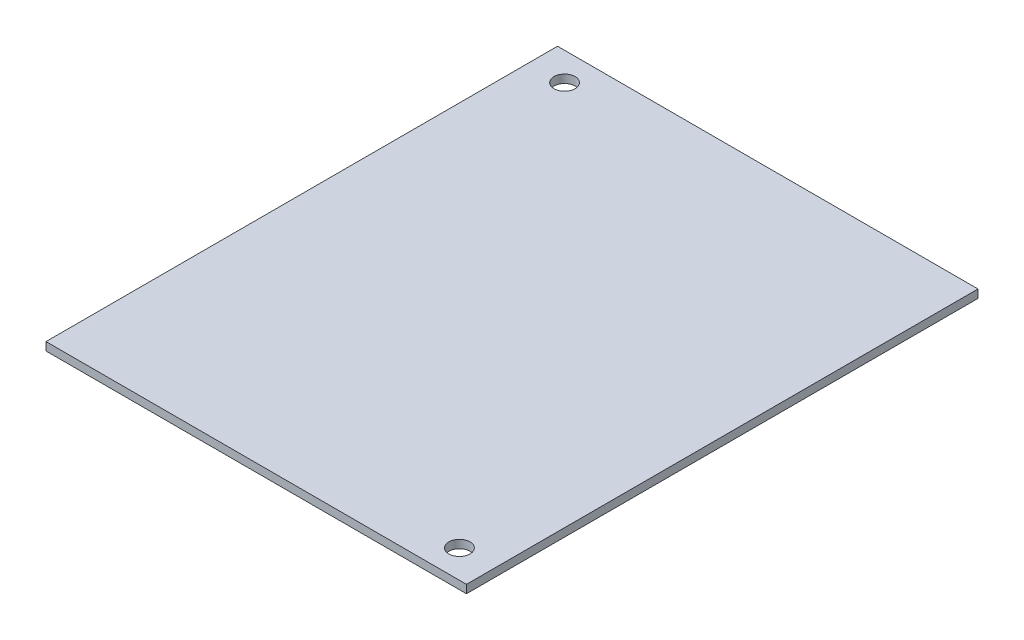
from build123d import *

# Parameters (mm, degrees)
SKETCH1_W           = 60
SKETCH1_H           = 73
SKETCH1_R           = 1.5025
BOSS_EXTRUDE1_DEPTH = 1.17


with BuildPart() as part:
    # Sketch1 → Boss-Extrude1 (new body)
    with BuildSketch(Plane(origin=(0, 0, 0), x_dir=(1, 0, 0), z_dir=(0, 1, 0))):
        Rectangle(SKETCH1_W, SKETCH1_H)
        with Locations((25, -32.5)):
            Circle(SKETCH1_R, mode=Mode.SUBTRACT)
        with Locations((-25, 32.5)):
            Circle(SKETCH1_R, mode=Mode.SUBTRACT)
    extrude(amount=BOSS_EXTRUDE1_DEPTH)


solid = part.part
